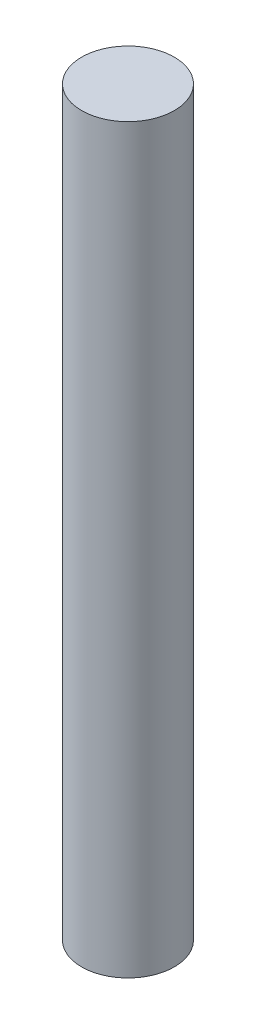
from build123d import *

# Parameters (mm, degrees)
SKETCH1_R           = 12.5
BOSS_EXTRUDE1_DEPTH = 200


with BuildPart() as part:
    # Sketch1 → Boss-Extrude1 (new body)
    with BuildSketch(Plane(origin=(0, 0, 0), x_dir=(1, 0, 0), z_dir=(0, 1, 0))):
        Circle(SKETCH1_R)
    extrude(amount=BOSS_EXTRUDE1_DEPTH)


solid = part.part
